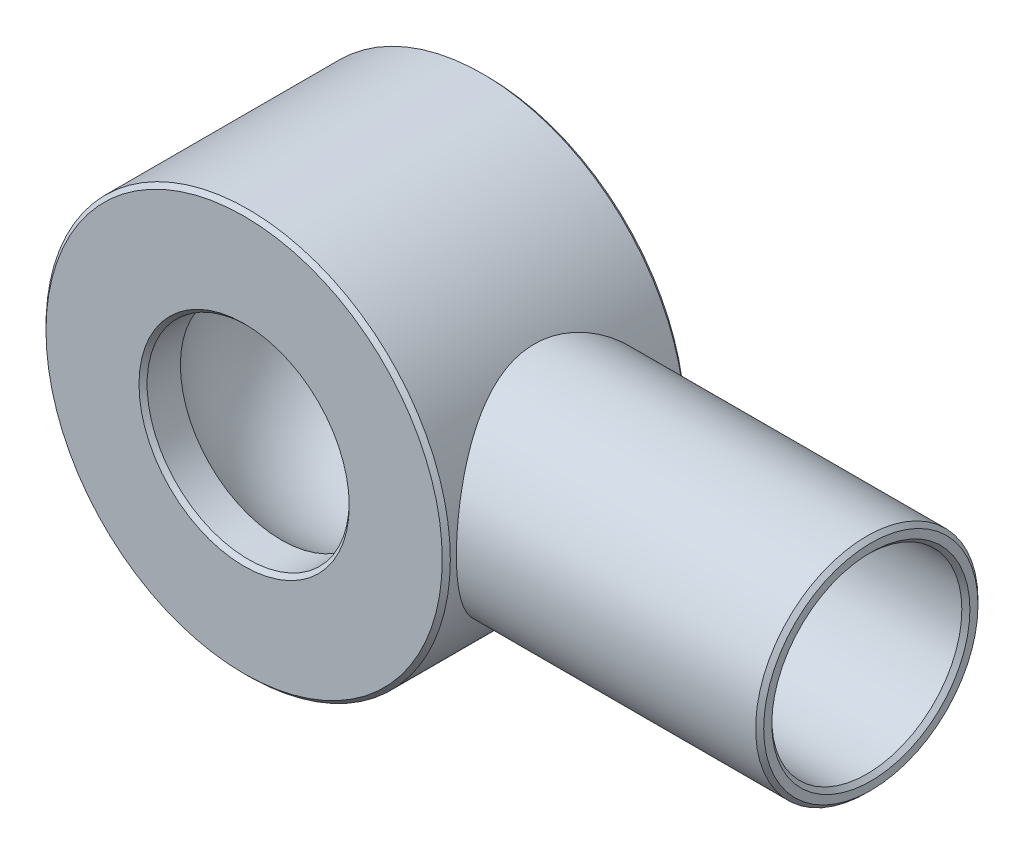
from build123d import *

# Parameters (mm, degrees)
BOSS_EXTRUDE1_DEPTH      = 30
BOSS_EXTRUDE1_DEPTH_BACK = 30
SKETCH3_R                = 50
SKETCH3_R_2              = 25
SKETCH5_R                = 27.5
BOSS_EXTRUDE2_DEPTH      = 90
SKETCH6_R                = 23.5
CUT_EXTRUDE1_DEPTH       = 35
CHAMFER1_SIZE            = 1
CHAMFER3_SIZE            = 1
CHAMFER5_SIZE            = 1
CHAMFER6_SIZE            = 1
CHAMFER7_SIZE            = 1


with BuildPart() as part:
    # Sketch3 → Boss-Extrude1 (new, two sides: drawn at the far end of the back side and taken through both)
    with BuildSketch(Plane.XY.offset(-BOSS_EXTRUDE1_DEPTH_BACK)):
        Circle(SKETCH3_R)
        Circle(SKETCH3_R_2, mode=Mode.SUBTRACT)
    extrude(amount=BOSS_EXTRUDE1_DEPTH + BOSS_EXTRUDE1_DEPTH_BACK)

    # Sketch4 → Cut-Revolve5 (revolve, cut)
    with BuildSketch(Plane(origin=(0, 0, 0), x_dir=(0, 0, -1), z_dir=(1, 0, 0))):
        with BuildLine():
            Line((0, 32.5), (0, -32.5))
            ThreePointArc((0, -32.5), (32.5, 0), (0, 32.5))
        make_face()
    revolve(axis=Axis((0, 32.5, 0), (0, -1, 0)), mode=Mode.SUBTRACT)

    # Sketch5 → Boss-Extrude2 (add)
    with BuildSketch(Plane(origin=(125, 0, 0), x_dir=(0, 0, -1), z_dir=(1, 0, 0))):
        Circle(SKETCH5_R)
    extrude(amount=-BOSS_EXTRUDE2_DEPTH)

    # Sketch6 → Cut-Extrude1 (cut)
    with BuildSketch(Plane(origin=(125, 0, 0), x_dir=(0, 0, -1), z_dir=(1, 0, 0))):
        Circle(SKETCH6_R)
    extrude(amount=-CUT_EXTRUDE1_DEPTH, mode=Mode.SUBTRACT)

    # Chamfer1
    chamfer1_edges = [part.edges().sort_by_distance(p)[0] for p in [
        (-50, 0, -30),
    ]]
    chamfer(chamfer1_edges, length=CHAMFER1_SIZE)

    # Chamfer3
    chamfer3_edges = [part.edges().sort_by_distance(p)[0] for p in [
        (-25, 0, -30),
    ]]
    chamfer(chamfer3_edges, length=CHAMFER3_SIZE)

    # Chamfer5
    chamfer5_edges = [part.edges().sort_by_distance(p)[0] for p in [
        (-50, 0, 30),
    ]]
    chamfer(chamfer5_edges, length=CHAMFER5_SIZE)

    # Chamfer6
    chamfer6_edges = [part.edges().sort_by_distance(p)[0] for p in [
        (-25, 0, 30),
    ]]
    chamfer(chamfer6_edges, length=CHAMFER6_SIZE)

    # Chamfer7
    chamfer7_edges = [part.edges().sort_by_distance(p)[0] for p in [
        (125, 0, 23.5),
        (125, 0, 27.5),
    ]]
    chamfer(chamfer7_edges, length=CHAMFER7_SIZE)


solid = part.part
